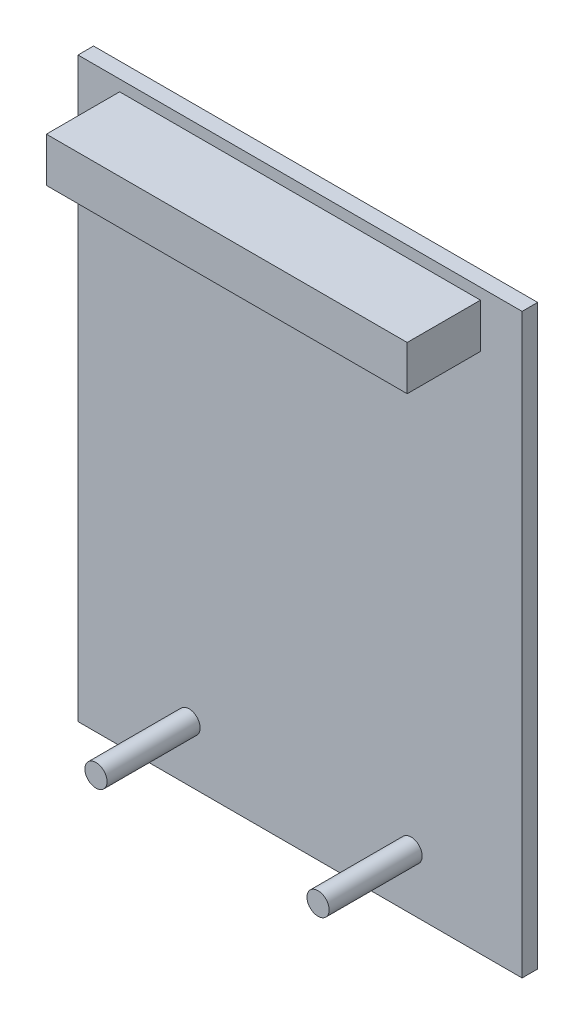
from build123d import *

# Parameters (mm, degrees)
SKETCH1_W           = 50.8
SKETCH1_H           = 66.04
BOSS_EXTRUDE1_DEPTH = 1.778
SKETCH2_W           = 41.275
SKETCH2_H           = 5.08
BOSS_EXTRUDE2_DEPTH = 8.382
SKETCH3_R           = 1.27
BOSS_EXTRUDE3_DEPTH = 10.6426


with BuildPart() as part:
    # Sketch1 → Boss-Extrude1 (new body)
    with BuildSketch(Plane.XY):
        with Locations((25.4, 33.02)):
            Rectangle(SKETCH1_W, SKETCH1_H)
    extrude(amount=BOSS_EXTRUDE1_DEPTH)

    # Sketch2 → Boss-Extrude2 (add)
    with BuildSketch(Plane.XY.offset(1.778)):
        with Locations((25.4, 62.23)):
            Rectangle(SKETCH2_W, SKETCH2_H)
    extrude(amount=BOSS_EXTRUDE2_DEPTH)

    # Sketch3 → Boss-Extrude3 (add)
    with BuildSketch(Plane.XY.offset(1.778)):
        with Locations((12.7, 6.35)):
            Circle(SKETCH3_R)
        with Locations((38.1, 6.35)):
            Circle(SKETCH3_R)
    extrude(amount=BOSS_EXTRUDE3_DEPTH)


solid = part.part
